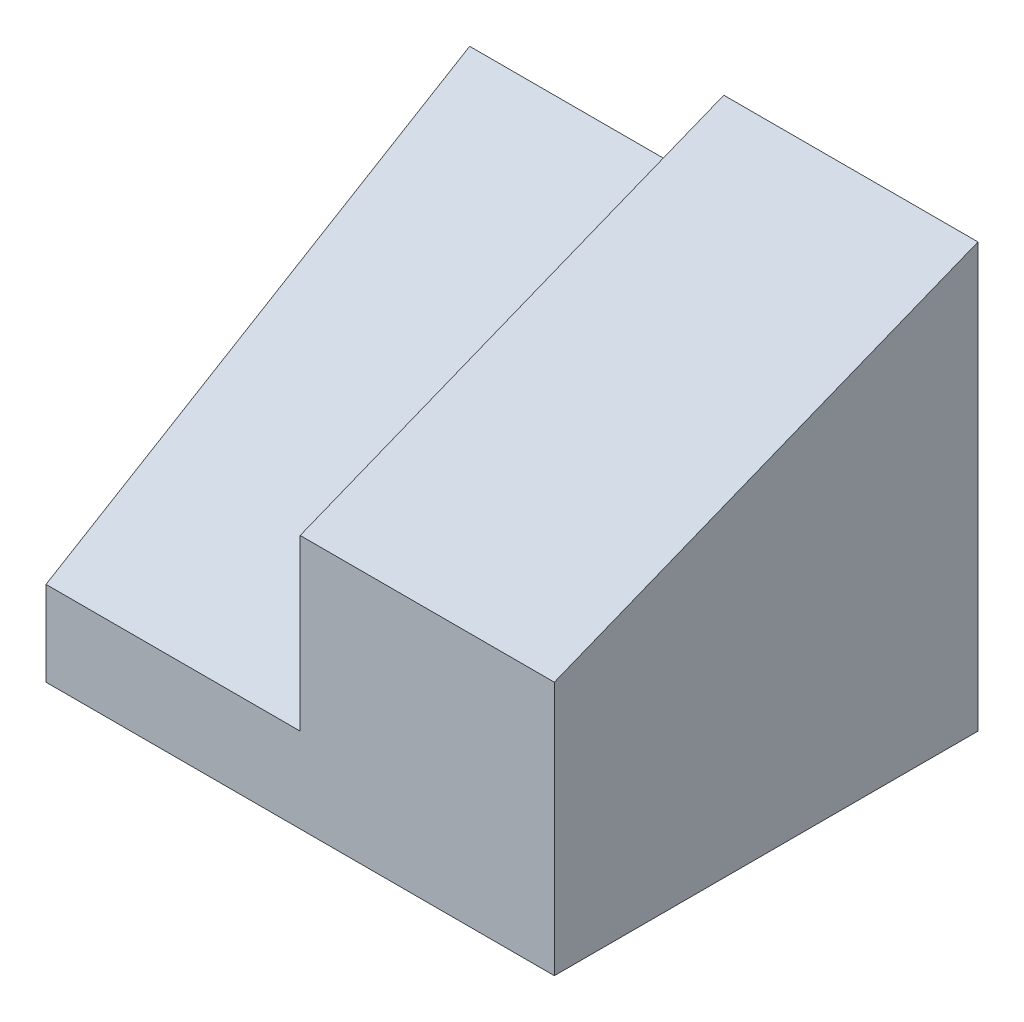
from build123d import *

# Parameters (mm, degrees)
BOSS_EXTRUDE1_DEPTH = 25
BOSS_EXTRUDE2_DEPTH = 15
BOSS_EXTRUDE3_DEPTH = 15


with BuildPart() as part:
    # Sketch1 → Boss-Extrude1 (new body)
    with BuildSketch(Plane.XY):
        Polygon((-30, 5), (-15, 5), (-15, 15), (0, 15), (0, 0), (-30, 0), align=None)
    extrude(amount=BOSS_EXTRUDE1_DEPTH)

    # Sketch2 → Boss-Extrude2 (add)
    with BuildSketch(Plane(origin=(0, 0, 0), x_dir=(0, 0, -1), z_dir=(1, 0, 0))):
        Polygon((0, 15), (0, 25), (-25, 15), align=None)
    extrude(amount=-BOSS_EXTRUDE2_DEPTH)

    # Sketch3 → Boss-Extrude3 (add)
    with BuildSketch(Plane.ZY.offset(15)):
        Polygon((0, 5), (0, 20), (25, 5), align=None)
    extrude(amount=BOSS_EXTRUDE3_DEPTH)


solid = part.part
